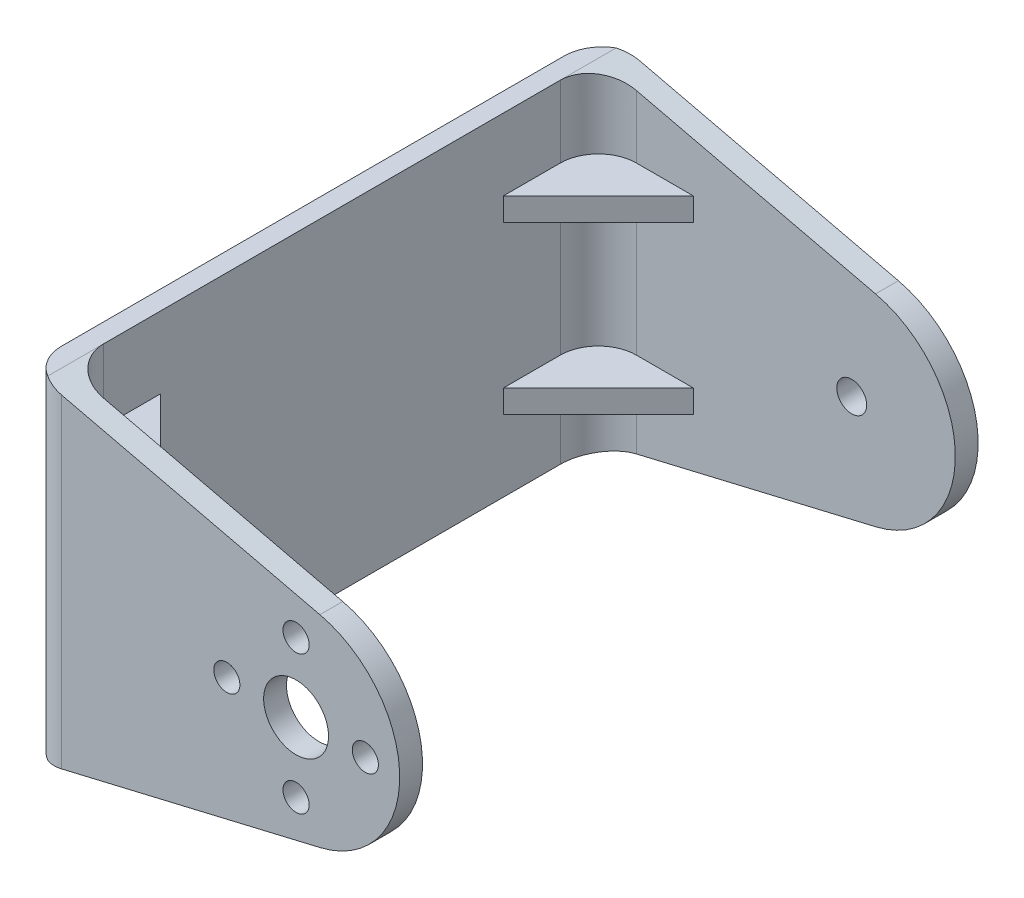
from build123d import *

# Parameters (mm, degrees)
BOSS_EXTRUDE1_DEPTH = 2.4
BOSS_EXTRUDE2_DEPTH = 2.4
SKETCH2_W           = 2
SKETCH2_H           = 35
BOSS_EXTRUDE3_DEPTH = 60.848228
CUT_EXTRUDE1_REACH  = 62.848
SKETCH4_R           = 1.575
CUT_EXTRUDE2_REACH  = 62.848
SKETCH6_R           = 3.41
SKETCH6_R_2         = 1.375
FILLET1_R           = 4
BOSS_EXTRUDE4_DEPTH = 1.2
BOSS_EXTRUDE5_DEPTH = 1.2


with BuildPart() as part:
    # Sketch1 → Boss-Extrude1 (new body)
    with BuildSketch(Plane.XY):
        with BuildLine():
            Line((12.127473017, -0.607666052), (-17.03, -7.5))
            Line((-17.03, -7.5), (-17.03, 27.5))
            Line((-17.03, 27.5), (12.127473017, 20.607666052))
            ThreePointArc((12.127473017, 20.607666052), (20.52, 10), (12.127473017, -0.607666052))
        make_face()
    extrude(amount=BOSS_EXTRUDE1_DEPTH)



with BuildPart() as body_2:
    # Sketch3 → Boss-Extrude2 (new body)
    with BuildSketch(Plane(origin=(0, 0, -56.04822809), x_dir=(-1, 0, 0), z_dir=(0, 0, -1))):
        with BuildLine():
            Line((-12.127473017, -0.607666052), (17.03, -7.5))
            Line((17.03, -7.5), (17.03, 27.5))
            Line((17.03, 27.5), (-12.127473017, 20.607666052))
            ThreePointArc((-12.127473017, 20.607666052), (-20.52, 10), (-12.127473017, -0.607666052))
        make_face()
    extrude(amount=BOSS_EXTRUDE2_DEPTH)


with BuildPart() as part_1:
    add(part.part)

    add(body_2.part)  # Boss-Extrude3 merges body 2
    # Sketch2 → Boss-Extrude3 (add)
    with BuildSketch(Plane.XY.offset(2.4)):
        with Locations((-18.03, 10)):
            Rectangle(SKETCH2_W, SKETCH2_H)
    extrude(amount=-BOSS_EXTRUDE3_DEPTH)

    # Sketch4 → Cut-Extrude1 (cut, up to next)
    with BuildSketch(Plane(origin=(0, 0, -58.44822809), x_dir=(-1, 0, 0), z_dir=(0, 0, -1)), mode=Mode.PRIVATE) as cut_extrude1_sk1:
        with Locations((-9.62, 10)):
            Circle(SKETCH4_R)
    cut_extrude1_tool1 = extrude(cut_extrude1_sk1.sketch, amount=-CUT_EXTRUDE1_REACH, mode=Mode.PRIVATE) & part_1.part
    add(cut_extrude1_tool1.solids().sort_by_distance((9.62, 10, -58.448228))[0], mode=Mode.SUBTRACT)

    # Sketch6 → Cut-Extrude2 (cut, up to next)
    with BuildSketch(Plane.XY.offset(2.4), mode=Mode.PRIVATE) as cut_extrude2_sk1:
        with Locations((9.62, 10)):
            Circle(SKETCH6_R)
    cut_extrude2_tool1 = extrude(cut_extrude2_sk1.sketch, amount=-CUT_EXTRUDE2_REACH, mode=Mode.PRIVATE) & part_1.part
    add(cut_extrude2_tool1.solids().sort_by_distance((9.62, 10, 2.4))[0], mode=Mode.SUBTRACT)
    # Sketch6 → Cut-Extrude2 (cut, up to next)
    with BuildSketch(Plane.XY.offset(2.4), mode=Mode.PRIVATE) as cut_extrude2_sk2:
        with Locations((2.335, 10)):
            Circle(SKETCH6_R_2)
    cut_extrude2_tool2 = extrude(cut_extrude2_sk2.sketch, amount=-CUT_EXTRUDE2_REACH, mode=Mode.PRIVATE) & part_1.part
    add(cut_extrude2_tool2.solids().sort_by_distance((2.335, 10, 2.4))[0], mode=Mode.SUBTRACT)
    # Sketch6 → Cut-Extrude2 (cut, up to next)
    with BuildSketch(Plane.XY.offset(2.4), mode=Mode.PRIVATE) as cut_extrude2_sk3:
        with Locations((9.62, 17.285)):
            Circle(SKETCH6_R_2)
    cut_extrude2_tool3 = extrude(cut_extrude2_sk3.sketch, amount=-CUT_EXTRUDE2_REACH, mode=Mode.PRIVATE) & part_1.part
    add(cut_extrude2_tool3.solids().sort_by_distance((9.62, 17.285, 2.4))[0], mode=Mode.SUBTRACT)
    # Sketch6 → Cut-Extrude2 (cut, up to next)
    with BuildSketch(Plane.XY.offset(2.4), mode=Mode.PRIVATE) as cut_extrude2_sk4:
        with Locations((16.905, 10)):
            Circle(SKETCH6_R_2)
    cut_extrude2_tool4 = extrude(cut_extrude2_sk4.sketch, amount=-CUT_EXTRUDE2_REACH, mode=Mode.PRIVATE) & part_1.part
    add(cut_extrude2_tool4.solids().sort_by_distance((16.905, 10, 2.4))[0], mode=Mode.SUBTRACT)
    # Sketch6 → Cut-Extrude2 (cut, up to next)
    with BuildSketch(Plane.XY.offset(2.4), mode=Mode.PRIVATE) as cut_extrude2_sk5:
        with Locations((9.62, 2.715)):
            Circle(SKETCH6_R_2)
    cut_extrude2_tool5 = extrude(cut_extrude2_sk5.sketch, amount=-CUT_EXTRUDE2_REACH, mode=Mode.PRIVATE) & part_1.part
    add(cut_extrude2_tool5.solids().sort_by_distance((9.62, 2.715, 2.4))[0], mode=Mode.SUBTRACT)

    # Fillet1
    fillet1_edges = [part_1.edges().sort_by_distance(p)[0] for p in [
        (-19.03, 10, -58.448228),
        (-19.03, 10, 2.4),
        (-17.03, 10, 0),
        (-17.03, 10, -56.04822809),
    ]]
    fillet(fillet1_edges, radius=FILLET1_R)

    # Sketch9 → Boss-Extrude4 (add, symmetric)
    with BuildSketch(Plane(origin=(0, 18.75, 0), x_dir=(-1, 0, 0), z_dir=(0, -1, 0))):
        Polygon((17.03, 46.04822809), (7.03, 56.04822809), (17.03, 56.04822809), align=None)
        Polygon((17.03, 10), (17.03, 0), (7.03, 0), align=None)
    extrude(amount=BOSS_EXTRUDE4_DEPTH, both=True)

    # Sketch10 → Boss-Extrude5 (add, symmetric)
    with BuildSketch(Plane(origin=(0, 1.25, 0), x_dir=(-1, 0, 0), z_dir=(0, -1, 0))):
        Polygon((7.03, 56.04822809), (17.03, 56.04822809), (17.03, 46.04822809), align=None)
        Polygon((17.03, 10), (17.03, 0), (7.03, 0), align=None)
    extrude(amount=BOSS_EXTRUDE5_DEPTH, both=True)


solid = part_1.part
